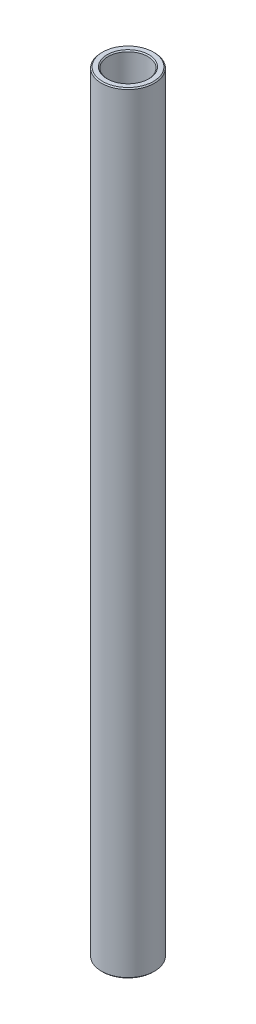
from build123d import *

# Parameters (mm, degrees)
SKETCH1_W     = 1.5875
SKETCH1_H     = 184.94375
CHAMFER1_SIZE = 0.254


with BuildPart() as part:
    # Sketch1 → Revolve1 (revolve)
    with BuildSketch(Plane.XY):
        with Locations((5.55625, 0)):
            Rectangle(SKETCH1_W, SKETCH1_H)
    revolve(axis=Axis((0, 11.60859375, 0), (0, -1, 0)))

    # Chamfer1
    chamfer1_edges = [part.edges().sort_by_distance(p)[0] for p in [
        (-4.7625, -92.471875, 0),
        (-6.35, -92.471875, 0),
        (-6.35, 92.471875, 0),
        (-4.7625, 92.471875, 0),
    ]]
    chamfer(chamfer1_edges, length=CHAMFER1_SIZE)


solid = part.part
